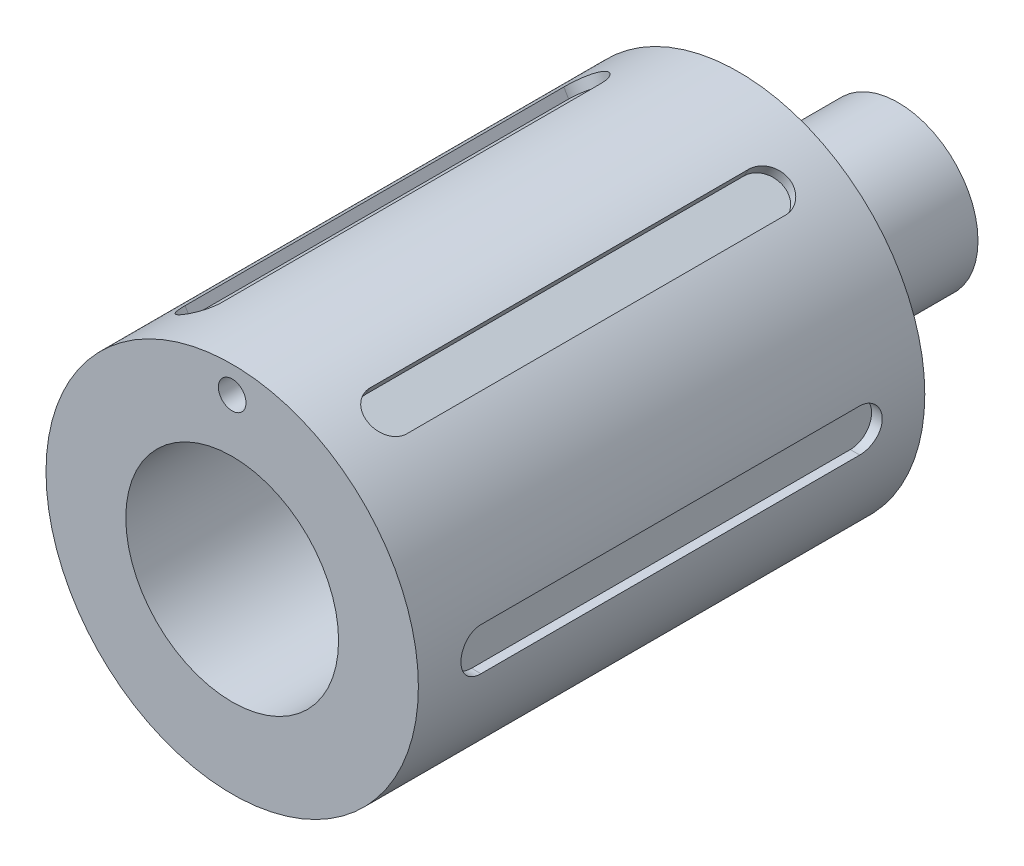
from build123d import *

# Parameters (mm, degrees)
CUT_EXTRUDE1_DEPTH              = 1.27
CIRPATTERN1_COUNT               = 6
F_3_4_0_13_DIAMETER_HOLE1_D     = 3.302
F_3_4_0_13_DIAMETER_HOLE1_DEPTH = 15.875
F_3_4_0_13_DIAMETER_HOLE1_TIP   = 0.992020882


with BuildPart() as part:
    # Sketch1 → Revolve1 (revolve)
    with BuildSketch(Plane(origin=(0, 0, 0), x_dir=(0, 0, -1), z_dir=(1, 0, 0))):
        Polygon((0, 12.7), (0, 22.225), (60.452, 22.225), (60.452, 9.525), (79.502, 9.525), (79.502, 0), (57.15, 0), (57.15, 12.7), align=None)
    revolve(axis=Axis((0, 0, 0), (0, 0, -1)))

    # Sketch2 → Cut-Extrude1 (cut)
    with BuildSketch(Plane(origin=(22.225, 0, 0), x_dir=(0, 0, -1), z_dir=(1, 0, 0))):
        with BuildLine():
            Line((7.62, 2.54), (52.832, 2.54))
            ThreePointArc((52.832, 2.54), (55.372, 0), (52.832, -2.54))
            Line((52.832, -2.54), (7.62, -2.54))
            ThreePointArc((7.62, -2.54), (5.08, 0), (7.62, 2.54))
        make_face()
    cut_extrude1 = extrude(amount=-CUT_EXTRUDE1_DEPTH, mode=Mode.SUBTRACT)

    # CirPattern1: Cut-Extrude1 ×6 about axis
    cirpattern1_axis = Axis((0, 0, 0), (0, 0, 1))
    for i in range(1, CIRPATTERN1_COUNT):
        add(cut_extrude1.rotate(cirpattern1_axis, i * 360 / CIRPATTERN1_COUNT), mode=Mode.SUBTRACT)

    # 3/4 (0.13) Diameter Hole1
    with Locations(Plane.XY):
        with Locations((0, 19.05)):
            Hole(F_3_4_0_13_DIAMETER_HOLE1_D / 2, depth=F_3_4_0_13_DIAMETER_HOLE1_DEPTH)
            with Locations((0, 0, -(F_3_4_0_13_DIAMETER_HOLE1_DEPTH + F_3_4_0_13_DIAMETER_HOLE1_TIP / 2))):  # 118° drill point
                Cone(0, F_3_4_0_13_DIAMETER_HOLE1_D / 2, F_3_4_0_13_DIAMETER_HOLE1_TIP, mode=Mode.SUBTRACT)


solid = part.part
